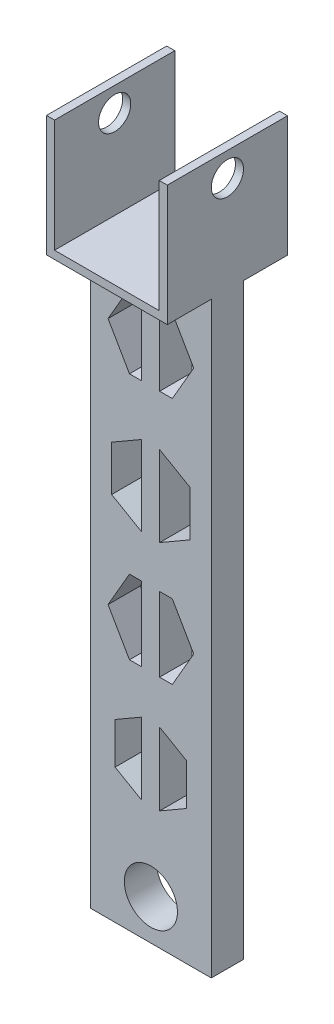
from build123d import *

# Parameters (mm, degrees)
SKETCH_1_W           = 15
SKETCH_1_H           = 4
EXTRUDE_1_DEPTH      = 85
SKETCH_17_W          = 15
SKETCH_17_H          = 12
SKETCH_17_H_2        = 3
EXTRUDE_2_DEPTH      = 10
EXTRUDE_2_DEPTH_BACK = 14
SKETCH_18_W          = 13
SKETCH_18_H          = 24
CUT_EXTRUDE_4_DEPTH  = 14
SKETCH_20_W          = 4.536667306
SKETCH_20_H          = 15
SKETCH_20_W_2        = 4.536667307
CUT_EXTRUDE_6_DEPTH  = 18
SKETCH_21_R          = 2
CUT_EXTRUDE_7_DEPTH  = 39
SKETCH_22_R          = 3.3
CUT_EXTRUDE_8_DEPTH  = 4
CUT_EXTRUDE_9_DEPTH  = 4


with BuildPart() as part:
    # 草图1 → 凸台-拉伸1 (new body)
    with BuildSketch(Plane(origin=(0, 0, 0), x_dir=(1, 0, 0), z_dir=(0, 1, 0))):
        with Locations((-12.365471303, -4.287695046)):
            Rectangle(SKETCH_1_W, SKETCH_1_H)
    extrude(amount=EXTRUDE_1_DEPTH)

    # 草图17 → 凸台-拉伸2 (add, two sides)
    with BuildSketch(Plane(origin=(0, 0, 2.287695046), x_dir=(-1, 0, 0), z_dir=(0, 0, -1))) as extrude_2_sk:
        with Locations((12.365471303, 79)):
            Rectangle(SKETCH_17_W, SKETCH_17_H)
        with Locations((12.365471303, 86.5)):
            Rectangle(SKETCH_17_W, SKETCH_17_H_2)
    extrude(amount=EXTRUDE_2_DEPTH)
    extrude(extrude_2_sk.sketch, amount=-EXTRUDE_2_DEPTH_BACK)

    # 草图18 → 切除-拉伸4 (cut)
    with BuildSketch(Plane(origin=(0, 88, 0), x_dir=(1, 0, 0), z_dir=(0, 1, 0))):
        with Locations((-12.365471303, -4.287695046)):
            Rectangle(SKETCH_18_W, SKETCH_18_H)
    extrude(amount=-CUT_EXTRUDE_4_DEPTH, mode=Mode.SUBTRACT)

    # 草图20 → 切除-拉伸6 (cut)
    with BuildSketch(Plane.ZY.offset(19.865471303)):
        with Locations((-5.443971301, 80.5)):
            Rectangle(SKETCH_20_W, SKETCH_20_H)
        with Locations((14.019361393, 80.5)):
            Rectangle(SKETCH_20_W_2, SKETCH_20_H)
    extrude(amount=-CUT_EXTRUDE_6_DEPTH, mode=Mode.SUBTRACT)

    # 草图21 → 切除-拉伸7 (cut)
    with BuildSketch(Plane.ZY.offset(19.865471303)):
        with Locations((4.287695046, 85.015112755)):
            Circle(SKETCH_21_R)
    extrude(amount=-CUT_EXTRUDE_7_DEPTH, mode=Mode.SUBTRACT)

    # 草图22 → 切除-拉伸8 (cut)
    with BuildSketch(Plane(origin=(0, 0, 2.287695046), x_dir=(-1, 0, 0), z_dir=(0, 0, -1))):
        with Locations((12.365471303, 5)):
            Circle(SKETCH_22_R)
    extrude(amount=-CUT_EXTRUDE_8_DEPTH, mode=Mode.SUBTRACT)

    # 草图23 → 切除-拉伸9 (cut)
    with BuildSketch(Plane.XY.offset(6.287695046)):
        Polygon((-13.537897134, 59.896284907), (-13.537897134, 69.113447), (-15.026236811, 69.113447), (-17.687002319, 64.504865953), (-15.026236811, 59.896284907), align=None)
        Polygon((-9.704705795, 59.896284907), (-7.043940288, 64.504865953), (-9.704705795, 69.113447), (-11.283232075, 69.113447), (-11.283232075, 59.896284907), align=None)
        Polygon((-13.537897134, 43.671503457), (-13.537897134, 53.576980938), (-17.240881786, 51.439061752), (-17.240881786, 45.809422642), align=None)
        Polygon((-7.49006082, 51.439061752), (-11.283232075, 53.629050197), (-11.283232075, 43.619434197), (-7.49006082, 45.809422642), align=None)
        Polygon((-13.537897134, 29.143330966), (-13.537897134, 38.360493059), (-15.026236811, 38.360493059), (-17.687002319, 33.751912013), (-15.026236811, 29.143330966), align=None)
        Polygon((-9.704705795, 38.360493059), (-11.283232075, 38.360493059), (-11.283232075, 29.143330966), (-9.704705795, 29.143330966), (-7.043940288, 33.751912013), align=None)
        Polygon((-13.537897134, 14.814321043), (-13.537897134, 23.721128572), (-16.808445012, 21.832876874), (-16.808445012, 16.70257274), align=None)
        Polygon((-7.922497595, 21.832876874), (-11.283232075, 23.773197831), (-11.283232075, 14.762251783), (-7.922497595, 16.70257274), align=None)
    extrude(amount=-CUT_EXTRUDE_9_DEPTH, mode=Mode.SUBTRACT)


solid = part.part
